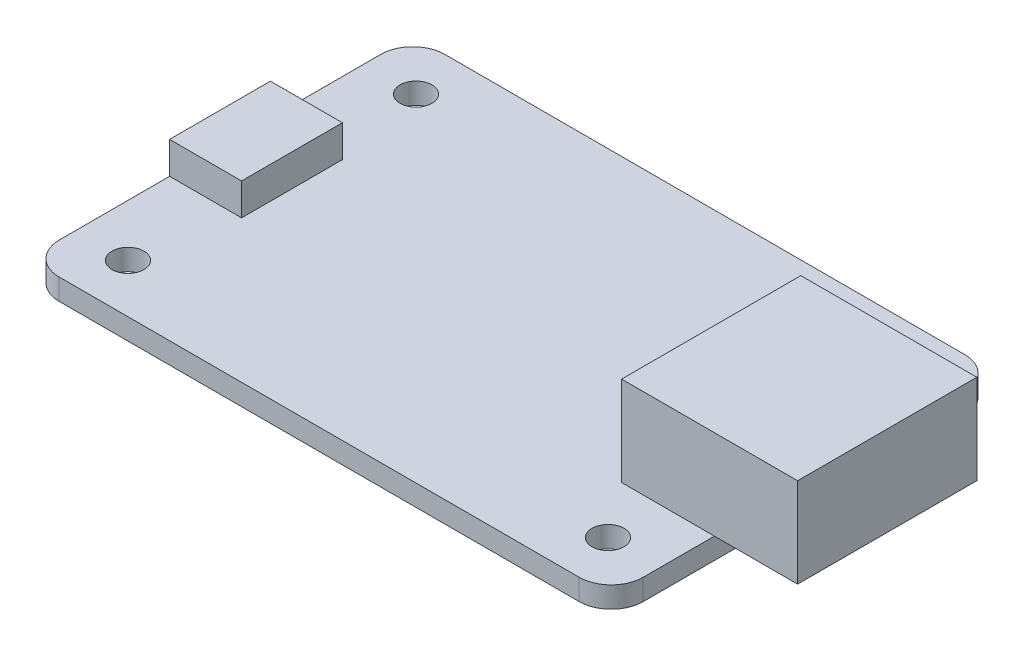
from build123d import *

# Parameters (mm, degrees)
SKETCH1_W           = 46.355
SKETCH1_H           = 30.607
SKETCH1_R           = 1.27
BOSS_EXTRUDE1_DEPTH = 1.6764
SKETCH2_W           = 13.97
SKETCH2_H           = 14.224
BOSS_EXTRUDE2_DEPTH = 7.112
SKETCH3_W           = 5.715
SKETCH3_H           = 8.001
BOSS_EXTRUDE3_DEPTH = 2.54
FILLET1_R           = 2.54


with BuildPart() as part:
    # Sketch1 → Boss-Extrude1 (new body)
    with BuildSketch(Plane(origin=(0, 0, 0), x_dir=(1, 0, 0), z_dir=(0, 1, 0))):
        with Locations((23.1775, 15.3035)):
            Rectangle(SKETCH1_W, SKETCH1_H)
        with Locations((4.1275, 26.7335)):
            Circle(SKETCH1_R, mode=Mode.SUBTRACT)
        with Locations((42.2275, 26.7335)):
            Circle(SKETCH1_R, mode=Mode.SUBTRACT)
        with Locations((4.1275, 3.8735)):
            Circle(SKETCH1_R, mode=Mode.SUBTRACT)
        with Locations((42.2275, 3.8735)):
            Circle(SKETCH1_R, mode=Mode.SUBTRACT)
    extrude(amount=BOSS_EXTRUDE1_DEPTH)

    # Sketch2 → Boss-Extrude2 (add)
    with BuildSketch(Plane(origin=(0, 1.6764, 0), x_dir=(1, 0, 0), z_dir=(0, 1, 0))):
        with Locations((45.974, 15.3035)):
            Rectangle(SKETCH2_W, SKETCH2_H)
    extrude(amount=BOSS_EXTRUDE2_DEPTH)

    # Sketch3 → Boss-Extrude3 (add)
    with BuildSketch(Plane(origin=(0, 1.6764, 0), x_dir=(1, 0, 0), z_dir=(0, 1, 0))):
        with Locations((2.8575, 15.3035)):
            Rectangle(SKETCH3_W, SKETCH3_H)
    extrude(amount=BOSS_EXTRUDE3_DEPTH)

    # Fillet1
    fillet1_edges = [part.edges().sort_by_distance(p)[0] for p in [
        (0, 0.8382, -30.607),
        (46.355, 0.8382, -30.607),
        (46.355, 0.8382, 0),
        (0, 0.8382, 0),
    ]]
    fillet(fillet1_edges, radius=FILLET1_R)


solid = part.part
